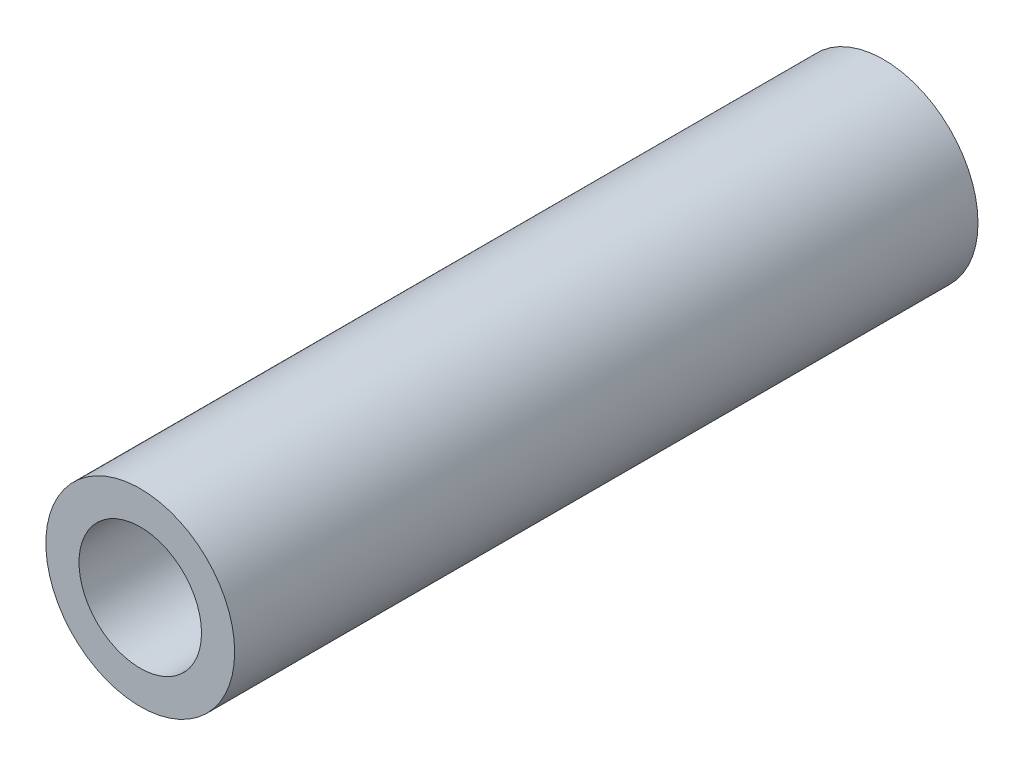
from build123d import *

# Parameters (mm, degrees)
SKETCH1_R           = 31.75
SKETCH1_R_2         = 20.6
BOSS_EXTRUDE1_DEPTH = 250


with BuildPart() as part:
    # Sketch1 → Boss-Extrude1 (new body)
    with BuildSketch(Plane.XY):
        Circle(SKETCH1_R)
        Circle(SKETCH1_R_2, mode=Mode.SUBTRACT)
    extrude(amount=BOSS_EXTRUDE1_DEPTH)


solid = part.part
